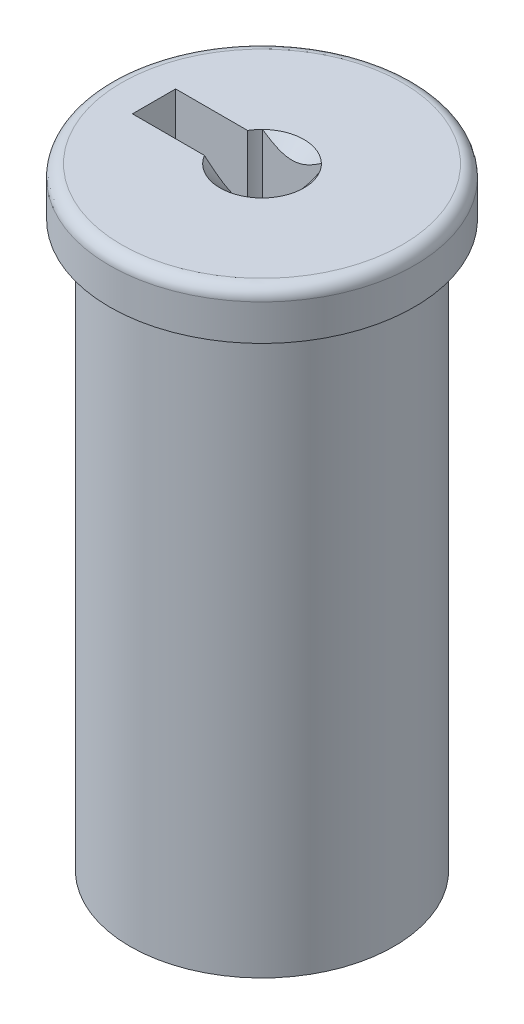
from build123d import *

# Parameters (mm, degrees)
SKETCH1_W           = 6.35
SKETCH1_H           = 1.996855346
SKETCH2_R           = 5.5
BOSS_EXTRUDE1_DEPTH = 23.5
CUT_EXTRUDE1_DEPTH  = 10
FILLET1_R           = 0.5


with BuildPart() as part:
    # Sketch1 → Revolve1 (revolve)
    with BuildSketch(Plane(origin=(0, 0, 0), x_dir=(-1, 0, 0), z_dir=(0, 0, -1))):
        with Locations((-3.175, 0.998427673)):
            Rectangle(SKETCH1_W, SKETCH1_H)
    revolve(axis=Axis((0, 0, 0), (0, 1, 0)))

    # Sketch2 → Boss-Extrude1 (add)
    with BuildSketch(Plane.XZ):
        Circle(SKETCH2_R)
    extrude(amount=BOSS_EXTRUDE1_DEPTH)

    # Sketch3 → Cut-Extrude1 (cut)
    with BuildSketch(Plane(origin=(0, 1.996855346, 0), x_dir=(-1, 0, 0), z_dir=(0, 1, 0))):
        with BuildLine():
            Line((4.499166898, 0.9), (-1.500833102, 0.9))
            Line((-1.500833102, 0.9), (-1.500833102, -0.9))
            ThreePointArc((-1.500833102, -0.9), (-1.373979193, -1.083827098), (-1.224744871, -1.25))
            Line((-1.224744871, -1.25), (1.224744871, -1.25))
            ThreePointArc((1.224744871, -1.25), (1.373979193, -1.083827098), (1.500833102, -0.9))
            Line((1.500833102, -0.9), (4.499166898, -0.9))
            Line((4.499166898, -0.9), (4.499166898, 0.9))
        make_face()
    extrude(amount=-CUT_EXTRUDE1_DEPTH, mode=Mode.SUBTRACT)

    # Fillet1
    fillet1_edges = [part.edges().sort_by_distance(p)[0] for p in [
        (-6.35, 1.996855346, 0),
    ]]
    fillet(fillet1_edges, radius=FILLET1_R)

    # Cut-Extrude2 cone 1 section (through the dimple's axis) → Cut-Extrude2 (revolve, cut)
    with BuildSketch(Plane(origin=(0, 1.996855346, 0), x_dir=(0, 0, 1), z_dir=(1, 0, 0))):
        Polygon((0, 0), (1.75, 0), (0, 1.75), align=None)
    revolve(axis=Axis((0, 1.996855346, 0), (0, -1, 0)), mode=Mode.SUBTRACT)


solid = part.part
